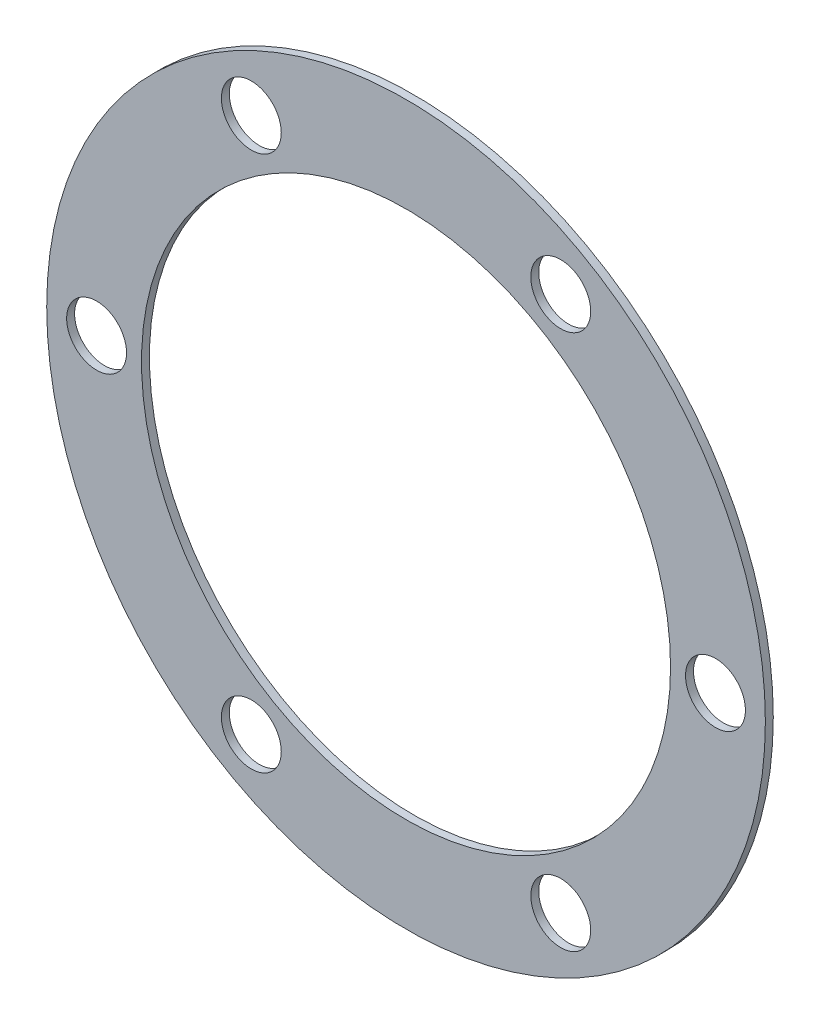
from build123d import *

# Parameters (mm, degrees)
SKETCH1_R           = 18
SKETCH1_R_2         = 1.5
SKETCH1_R_3         = 13.25
BOSS_EXTRUDE1_DEPTH = 0.396875


with BuildPart() as part:
    # Sketch1 → Boss-Extrude1 (new body)
    with BuildSketch(Plane.XY):
        Circle(SKETCH1_R)
        with Locations((-15.5, 0)):
            Circle(SKETCH1_R_2, mode=Mode.SUBTRACT)
        with Locations((-7.75, 13.423393759)):
            Circle(SKETCH1_R_2, mode=Mode.SUBTRACT)
        with Locations((7.75, 13.423393759)):
            Circle(SKETCH1_R_2, mode=Mode.SUBTRACT)
        with Locations((15.5, 0)):
            Circle(SKETCH1_R_2, mode=Mode.SUBTRACT)
        with Locations((7.75, -13.423393759)):
            Circle(SKETCH1_R_2, mode=Mode.SUBTRACT)
        with Locations((-7.75, -13.423393759)):
            Circle(SKETCH1_R_2, mode=Mode.SUBTRACT)
        Circle(SKETCH1_R_3, mode=Mode.SUBTRACT)
    extrude(amount=BOSS_EXTRUDE1_DEPTH)


solid = part.part
